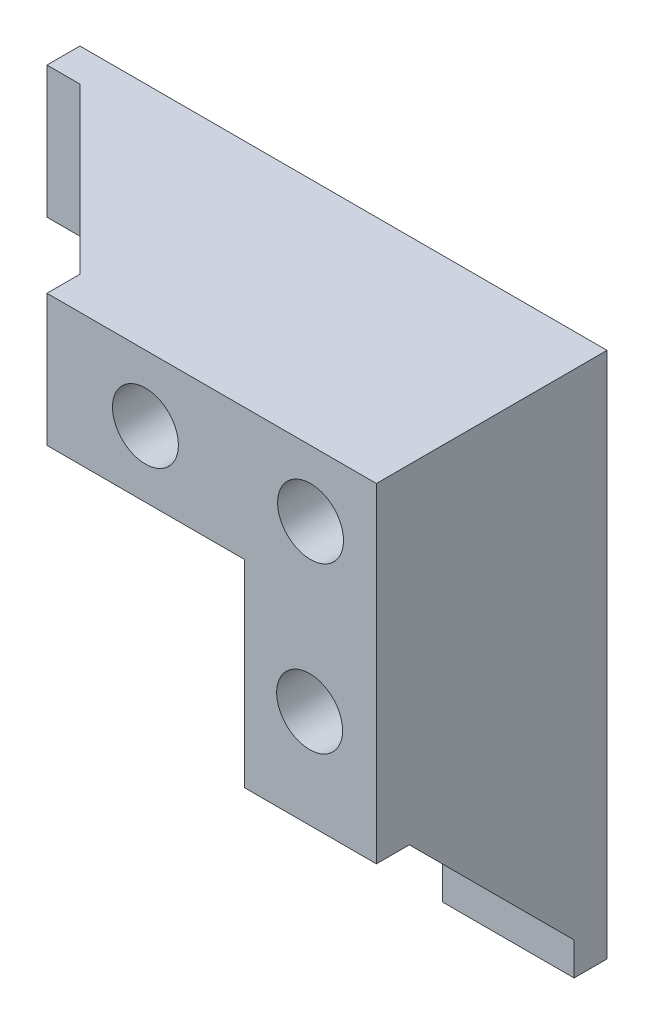
from build123d import *

# Parameters (mm, degrees)
EXTRUDE_1_DEPTH           = 35
HOLE_WIZARD_1_D           = 5.5
HOLE_WIZARD_1_CBORE_D     = 10
HOLE_WIZARD_1_CBORE_DEPTH = 27
SKETCH_6_R                = 5
SKETCH_6_R_2              = 2.75
SKETCH_6_R_3              = 2.861192155
CUT_EXTRUDE_1_DEPTH       = 27
SKETCH_8_R                = 2.75
SKETCH_8_R_2              = 2.861192155
CUT_EXTRUDE_2_DEPTH       = 35
CUT_EXTRUDE_3_DEPTH       = 35
CUT_EXTRUDE_4_DEPTH       = 35


with BuildPart() as part:
    # 草图1 → 凸台-拉伸1 (new body)
    with BuildSketch(Plane.XY):
        Polygon((-30.620689655, 42.965517241), (49.379310345, 42.965517241), (49.379310345, -37.034482759), (29.379310345, -37.034482759), (29.379310345, 22.965517241), (-30.620689655, 22.965517241), align=None)
    extrude(amount=EXTRUDE_1_DEPTH)

    # 孔1 (through all)
    with Locations(Plane(origin=(39.379310345, 32.965517241, 35), x_dir=(1, 0, 0), z_dir=(0, 0, 1))):
        with Locations((0, 0)):
            CounterBoreHole(HOLE_WIZARD_1_D / 2, HOLE_WIZARD_1_CBORE_D / 2, HOLE_WIZARD_1_CBORE_DEPTH)

    # 草图6 → 切除-拉伸1 (cut)
    with BuildSketch(Plane.XY.offset(35)):
        with Locations((14.324422016, 32.985524686)):
            Circle(SKETCH_6_R)
        with Locations((14.324422016, 32.985524686)):
            Circle(SKETCH_6_R_2, mode=Mode.SUBTRACT)
        with Locations((39.242589892, 7.916677332)):
            Circle(SKETCH_6_R)
        with Locations((39.242589892, 7.916677332)):
            Circle(SKETCH_6_R_3, mode=Mode.SUBTRACT)
        with Locations((39.242589892, -17.041261432)):
            Circle(SKETCH_6_R)
        with Locations((39.242589892, -17.041261432)):
            Circle(SKETCH_6_R_2, mode=Mode.SUBTRACT)
        with Locations((-10.641383775, 32.985524686)):
            Circle(SKETCH_6_R)
        with Locations((-10.641383775, 32.985524686)):
            Circle(SKETCH_6_R_2, mode=Mode.SUBTRACT)
    extrude(amount=-CUT_EXTRUDE_1_DEPTH, mode=Mode.SUBTRACT)

    # 草图8 → 切除-拉伸2 (cut)
    with BuildSketch(Plane.XY.offset(35)):
        with Locations((14.324422016, 32.985524686)):
            Circle(SKETCH_8_R)
        with Locations((39.242589892, 7.916677332)):
            Circle(SKETCH_8_R_2)
        with Locations((39.242589892, -17.041261432)):
            Circle(SKETCH_8_R)
        with Locations((-10.641383775, 32.985524686)):
            Circle(SKETCH_8_R)
    extrude(amount=-CUT_EXTRUDE_2_DEPTH, mode=Mode.SUBTRACT)

    # 草图9 → 切除-拉伸3 (cut)
    with BuildSketch(Plane(origin=(49.379310345, 0, 0), x_dir=(0, 0, -1), z_dir=(1, 0, 0))):
        Polygon((-5, -32.034482759), (-30, -7.034482759), (-35, -7.034482759), (-35, -37.034482759), (-5, -37.034482759), align=None)
    extrude(amount=-CUT_EXTRUDE_3_DEPTH, mode=Mode.SUBTRACT)

    # 草图10 → 切除-拉伸4 (cut)
    with BuildSketch(Plane(origin=(0, 42.965517241, 0), x_dir=(1, 0, 0), z_dir=(0, 1, 0))):
        Polygon((-30.620689655, -35), (-0.620689655, -35), (-0.620689655, -30), (-25.620689655, -5), (-30.620689655, -5), align=None)
    extrude(amount=-CUT_EXTRUDE_4_DEPTH, mode=Mode.SUBTRACT)


solid = part.part
